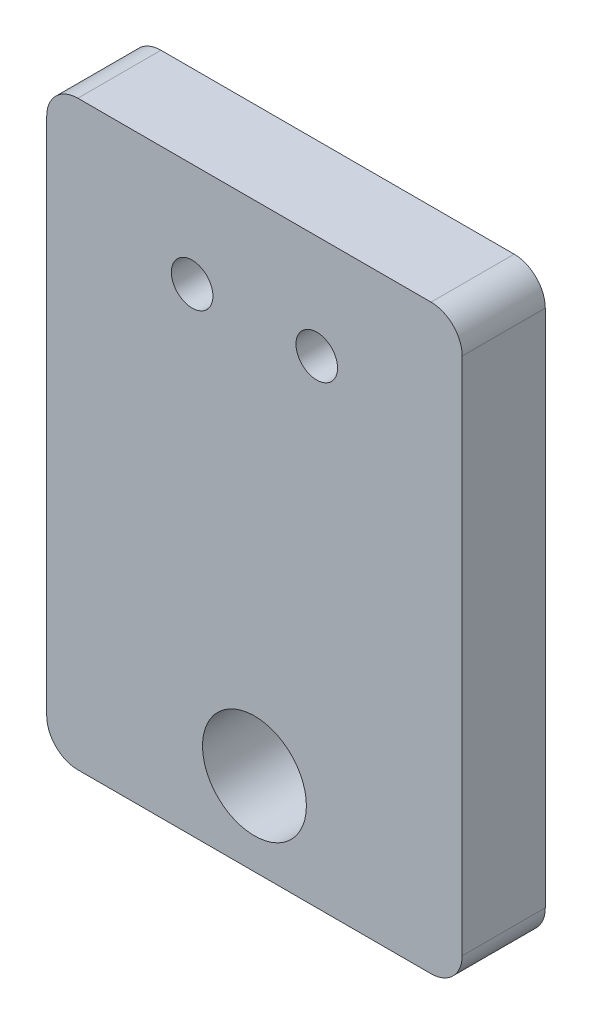
from build123d import *

# Parameters (mm, degrees)
SKETCH1_R           = 2.5
SKETCH1_R_2         = 1
BOSS_EXTRUDE1_DEPTH = 4


with BuildPart() as part:
    # Sketch1 → Boss-Extrude1 (new body)
    with BuildSketch(Plane.XY):
        with BuildLine():
            Line((-8.5, 14), (8.5, 14))
            ThreePointArc((8.5, 14), (9.560660172, 13.560660172), (10, 12.5))
            Line((10, 12.5), (10, -12.5))
            ThreePointArc((10, -12.5), (9.560660172, -13.560660172), (8.5, -14))
            Line((8.5, -14), (-8.5, -14))
            ThreePointArc((-8.5, -14), (-9.560660172, -13.560660172), (-10, -12.5))
            Line((-10, -12.5), (-10, 12.5))
            ThreePointArc((-10, 12.5), (-9.560660172, 13.560660172), (-8.5, 14))
        make_face()
        with Locations((0, -10)):
            Circle(SKETCH1_R, mode=Mode.SUBTRACT)
        with Locations((-3, 9)):
            Circle(SKETCH1_R_2, mode=Mode.SUBTRACT)
        with Locations((3, 9)):
            Circle(SKETCH1_R_2, mode=Mode.SUBTRACT)
    extrude(amount=BOSS_EXTRUDE1_DEPTH)


solid = part.part
